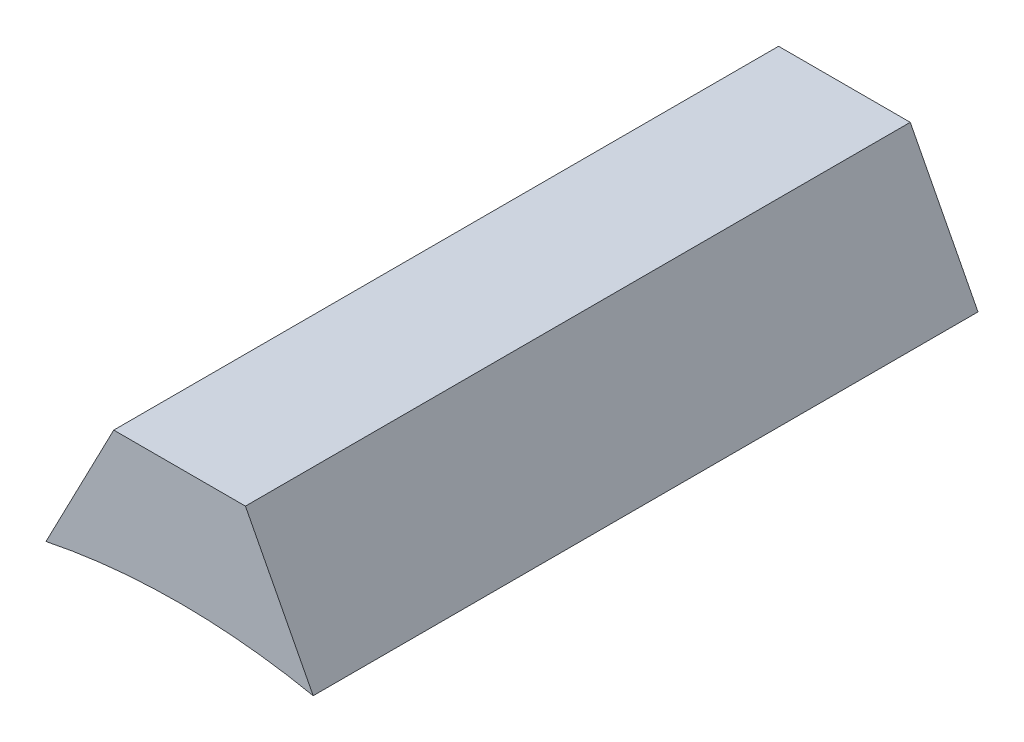
from build123d import *

# Parameters (mm, degrees)
BOSS_EXTRUDE2_DEPTH = 10


with BuildPart() as part:
    # Sketch1 → Boss-Extrude2 (new body)
    with BuildSketch(Plane.XY):
        with BuildLine():
            Line((0.990394049, 11.756567649), (-0.990394049, 11.756567649))
            Line((-0.990394049, 11.756567649), (-2.009578189, 9.795998954))
            ThreePointArc((-2.009578189, 9.795998954), (0, 10), (2.009578189, 9.795998954))
            Line((2.009578189, 9.795998954), (0.990394049, 11.756567649))
        make_face()
    extrude(amount=BOSS_EXTRUDE2_DEPTH)


solid = part.part
